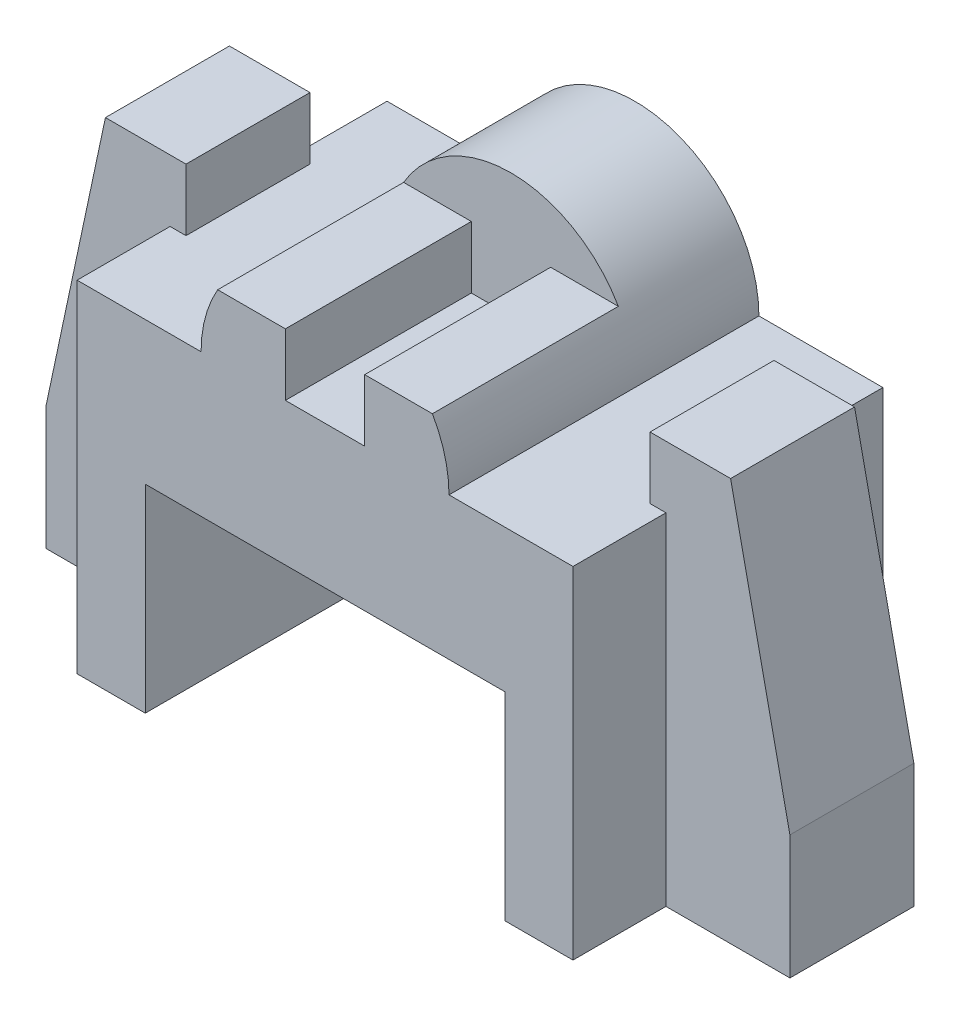
from build123d import *

# Parameters (mm, degrees)
BOSS_EXTRUDE1_DEPTH = 50
BOSS_EXTRUDE2_START = -35
BOSS_EXTRUDE2_DEPTH = 35.000012
CUT_EXTRUDE1_DEPTH  = 15
CUT_EXTRUDE2_DEPTH  = 15
SKETCH6_R           = 20
BOSS_EXTRUDE3_DEPTH = 50
CUT_EXTRUDE4_DEPTH  = 30
BOSS_EXTRUDE4_DEPTH = 30


with BuildPart() as part:
    # Sketch1 → Boss-Extrude1 (new body)
    with BuildSketch(Plane.XY):
        Polygon((0, 0), (11, 0), (11, 32), (69, 32), (69, 0), (80, 0), (80, 55), (0, 55), align=None)
    extrude(amount=-BOSS_EXTRUDE1_DEPTH)

    # Sketch2 → Boss-Extrude2 (add)
    with BuildSketch(Plane.XY.offset(BOSS_EXTRUDE2_START)):
        Polygon((0, 0), (-20, 0), (-20, 20), (-10.43, 65), (2.57, 65), (2.57, 55), (0, 55), align=None)
        Polygon((80, 0), (100, 0), (100, 20), (90.43, 65), (77.43, 65), (77.43, 55), (80, 55), align=None)
    extrude(amount=BOSS_EXTRUDE2_DEPTH)

    # Sketch3 → Cut-Extrude1 (cut)
    with BuildSketch(Plane.XY.offset(1.2e-05)):
        Polygon((0, 0), (0, 55), (2.57, 55), (2.57, 65), (-10.43, 65), (-20, 20), (-20, 0), align=None)
    extrude(amount=-CUT_EXTRUDE1_DEPTH, mode=Mode.SUBTRACT)

    # Sketch4 → Cut-Extrude2 (cut)
    with BuildSketch(Plane.XY):
        Polygon((80, 55), (80, 0), (100, 0), (100, 20), (90.43, 65), (77.43, 65), (77.43, 55), align=None)
    extrude(amount=-CUT_EXTRUDE2_DEPTH, mode=Mode.SUBTRACT)


with BuildPart() as cut_extrude2_kept_piece:
    # of the separate pieces the step leaves, the one the design keeps (cut_extrude2_pieces_kept)
    add(part.part.solids().sort_by_distance((0, 0, -35))[0])

    # Sketch6 → Boss-Extrude3 (add)
    with BuildSketch(Plane.XY):
        with Locations((40, 55)):
            Circle(SKETCH6_R)
    extrude(amount=-BOSS_EXTRUDE3_DEPTH)

    # Sketch8 → Cut-Extrude4 (cut)
    with BuildSketch(Plane.XY):
        with BuildLine():
            Line((20, 55), (60, 55))
            ThreePointArc((60, 55), (40, 75), (20, 55))
        make_face()
    extrude(amount=-CUT_EXTRUDE4_DEPTH, mode=Mode.SUBTRACT)

    # Sketch9 → Boss-Extrude4 (add)
    with BuildSketch(Plane.XY):
        with BuildLine():
            Line((20, 55), (33.6, 55))
            Line((33.6, 55), (33.6, 65))
            Line((33.6, 65), (22.679491924, 65))
            ThreePointArc((22.679491924, 65), (20.681483474, 60.176380902), (20, 55))
        make_face()
        with BuildLine():
            Line((60, 55), (46.4, 55))
            Line((46.4, 55), (46.4, 65))
            Line((46.4, 65), (57.320508076, 65))
            ThreePointArc((57.320508076, 65), (59.318516526, 60.176380902), (60, 55))
        make_face()
    extrude(amount=-BOSS_EXTRUDE4_DEPTH)


solid = cut_extrude2_kept_piece.part
